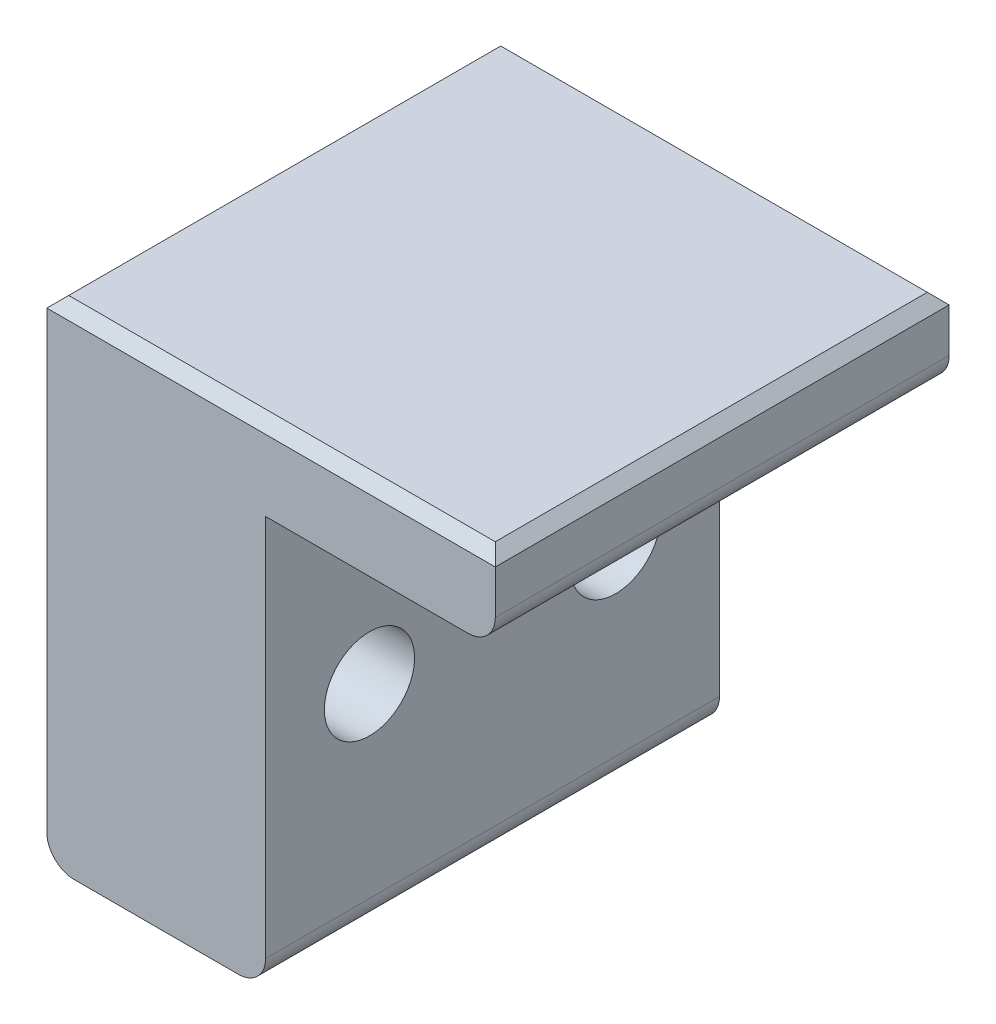
from build123d import *

# Parameters (mm, degrees)
BOSS_EXTRUDE1_DEPTH = 16.6
SKETCH2_R           = 1.65
CUT_EXTRUDE1_DEPTH  = 17.4
CHAMFER1_SIZE       = 0.4
FILLET1_R           = 1


with BuildPart() as part:
    # Sketch1 → Boss-Extrude1 (new body)
    with BuildSketch(Plane.XY):
        Polygon((0, 0), (8.4, 0), (8.4, 3), (-8, 3), (-8, -15), (0, -15), align=None)
    extrude(amount=BOSS_EXTRUDE1_DEPTH)

    # Sketch2 → Cut-Extrude1 (cut, through all)
    with BuildSketch(Plane.ZY.offset(8)):
        with Locations((3.8, -7.2)):
            Circle(SKETCH2_R)
        with Locations((12.8, -7.2)):
            Circle(SKETCH2_R)
    extrude(amount=-CUT_EXTRUDE1_DEPTH, mode=Mode.SUBTRACT)

    # Chamfer1
    chamfer1_edges = [part.edges().sort_by_distance(p)[0] for p in [
        (-8, 3, 8.3),
        (8.4, 3, 8.3),
        (0.2, 3, 16.6),
        (0.2, 3, 0),
    ]]
    chamfer(chamfer1_edges, length=CHAMFER1_SIZE)

    # Fillet1
    fillet1_edges = [part.edges().sort_by_distance(p)[0] for p in [
        (0, -15, 8.3),
        (-8, -15, 8.3),
        (8.4, 0, 8.3),
    ]]
    fillet(fillet1_edges, radius=FILLET1_R)


solid = part.part
